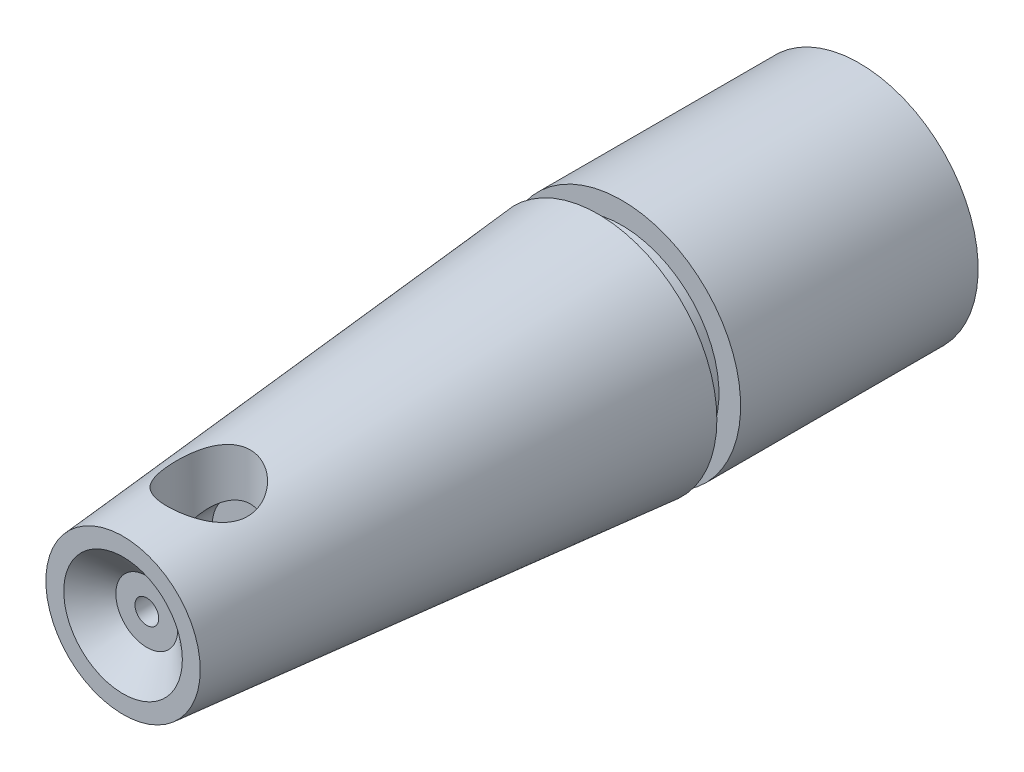
from build123d import *
from build123d.topology import SkipClean

# Parameters (mm, degrees)
SKETCH2_R           = 10
BOSS_EXTRUDE1_DEPTH = 40
BOSS_EXTRUDE1_TAPER = 5
SKETCH3_R           = 4.992752688
CUT_EXTRUDE1_DEPTH  = 2
CUT_EXTRUDE1_DRAFT  = -50
SKETCH5_R           = 1
CUT_EXTRUDE3_DEPTH  = 2
SKETCH6_R           = 3.5
CUT_EXTRUDE4_DEPTH  = 7
SKETCH13_R          = 3.5
CUT_EXTRUDE9_DEPTH  = 15
SKETCH16_R          = 2
CUT_EXTRUDE11_DEPTH = 16
SKETCH19_R          = 8.176600108
BOSS_EXTRUDE2_DEPTH = 2
SKETCH20_R          = 10
BOSS_EXTRUDE3_DEPTH = 20


with BuildPart() as part:
    # Sketch2 → Boss-Extrude1 (new body)
    with BuildSketch(Plane.XY):
        Circle(SKETCH2_R)
    extrude(amount=BOSS_EXTRUDE1_DEPTH, taper=BOSS_EXTRUDE1_TAPER)


with BuildPart() as cut_extrude1_tool:
    # Sketch3 → Cut-Extrude1 (with draft: the straight prism first)
    with BuildSketch(Plane.XY.offset(40)):
        Circle(SKETCH3_R)
    extrude(amount=-CUT_EXTRUDE1_DEPTH)
    # Cut-Extrude1: the draft: its side faces are tilted about the plane it starts from
    cut_extrude1_sides = [cut_extrude1_tool.faces().sort_by_distance(p)[0] for p in [
        (-4.992752688, 0, 39),
    ]]
    draft(cut_extrude1_sides, Plane.XY.offset(40), CUT_EXTRUDE1_DRAFT)


with BuildPart() as part_1:
    add(part.part)

    # Cut-Extrude1: cut by cut_extrude1_tool
    add(cut_extrude1_tool.part, mode=Mode.SUBTRACT)

    # Sketch5 → Cut-Extrude3 (cut)
    with BuildSketch(Plane.XY.offset(38)):
        Circle(SKETCH5_R)
    extrude(amount=-CUT_EXTRUDE3_DEPTH, mode=Mode.SUBTRACT)

    # Sketch6 → Cut-Extrude4 (cut)
    with BuildSketch(Plane.XY.offset(36)):
        Circle(SKETCH6_R)
    extrude(amount=-CUT_EXTRUDE4_DEPTH, mode=Mode.SUBTRACT)

    # Sketch13 → Cut-Extrude9 (cut)
    with SkipClean():  # the faces are left unmerged after this step: merging them gives an invalid solid
        with BuildSketch(Plane(origin=(0, 0, 0), x_dir=(1, 0, 0), z_dir=(0, 1, 0))):
            with Locations((0, -32.782879844)):
                Circle(SKETCH13_R)
        extrude(amount=CUT_EXTRUDE9_DEPTH, mode=Mode.SUBTRACT)

    # Sketch16 → Cut-Extrude11 (cut)
    with SkipClean():  # the faces are left unmerged after this step: merging them gives an invalid solid
        with BuildSketch(Plane(origin=(0, 0, 0), x_dir=(0, 0, -1), z_dir=(1, 0, 0))):
            with Locations((-32.694716643, 0)):
                Circle(SKETCH16_R)
        extrude(amount=-CUT_EXTRUDE11_DEPTH, mode=Mode.SUBTRACT)


with BuildPart() as body_2:
    # Sketch19 → Boss-Extrude2 (new body)
    with BuildSketch(Plane(origin=(0, 0, 0), x_dir=(-1, 0, 0), z_dir=(0, 0, -1))):
        Circle(SKETCH19_R)
    extrude(amount=BOSS_EXTRUDE2_DEPTH)

    # Sketch20 → Boss-Extrude3 (add)
    with BuildSketch(Plane(origin=(0, 0, -2), x_dir=(-1, 0, 0), z_dir=(0, 0, -1))):
        Circle(SKETCH20_R)
    extrude(amount=BOSS_EXTRUDE3_DEPTH)


solid = Compound([part_1.part, body_2.part])
